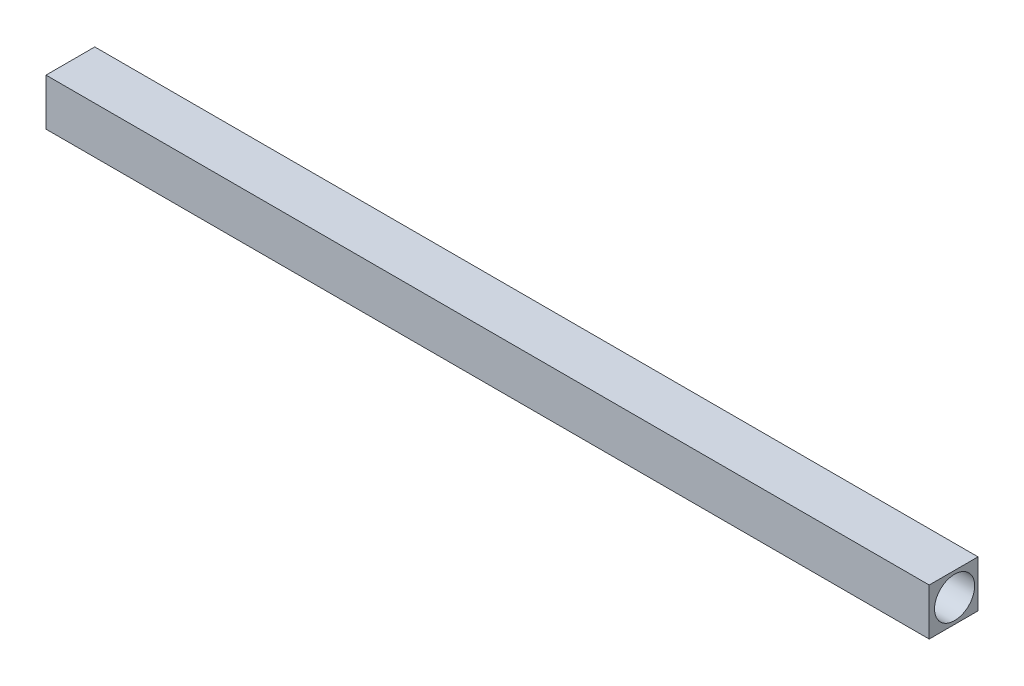
from build123d import *

# Parameters (mm, degrees)
SKETCH1_W           = 660
SKETCH1_H           = 36.458333333
BOSS_EXTRUDE1_DEPTH = 35
SKETCH2_R           = 15
CUT_EXTRUDE1_DEPTH  = 661


with BuildPart() as part:
    # Sketch1 → Boss-Extrude1 (new body)
    with BuildSketch(Plane(origin=(0, 0, 0), x_dir=(1, 0, 0), z_dir=(0, 1, 0))):
        with Locations((270.657487282, -18.229166666)):
            Rectangle(SKETCH1_W, SKETCH1_H)
    extrude(amount=BOSS_EXTRUDE1_DEPTH)

    # Sketch2 → Cut-Extrude1 (cut, through all)
    with BuildSketch(Plane(origin=(600.657487282, 0, 0), x_dir=(0, 0, -1), z_dir=(1, 0, 0))):
        with Locations((-17.5, 17.5)):
            Circle(SKETCH2_R)
    extrude(amount=-CUT_EXTRUDE1_DEPTH, mode=Mode.SUBTRACT)


solid = part.part
